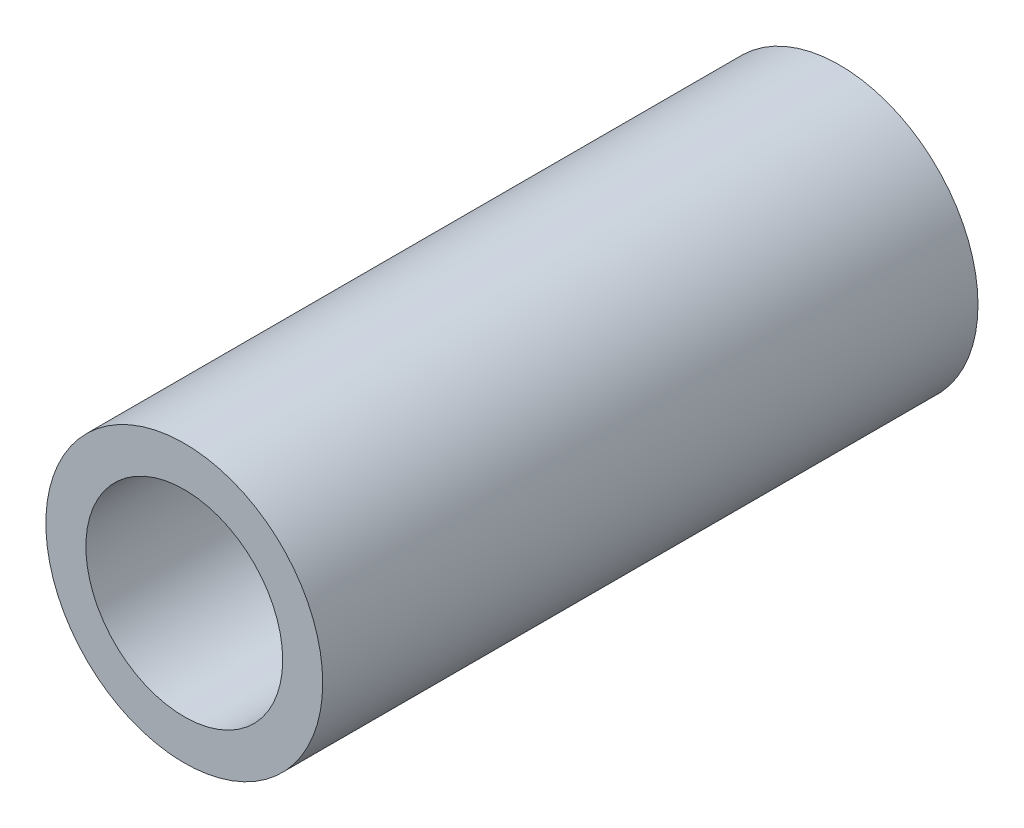
from build123d import *

# Parameters (mm, degrees)
SKETCH1_R           = 14.487499954
SKETCH1_R_2         = 10.299999974
BOSS_EXTRUDE1_DEPTH = 68.58


with BuildPart() as part:
    # Sketch1 → Boss-Extrude1 (new body)
    with BuildSketch(Plane.XY):
        Circle(SKETCH1_R)
        Circle(SKETCH1_R_2, mode=Mode.SUBTRACT)
    extrude(amount=BOSS_EXTRUDE1_DEPTH)


solid = part.part
